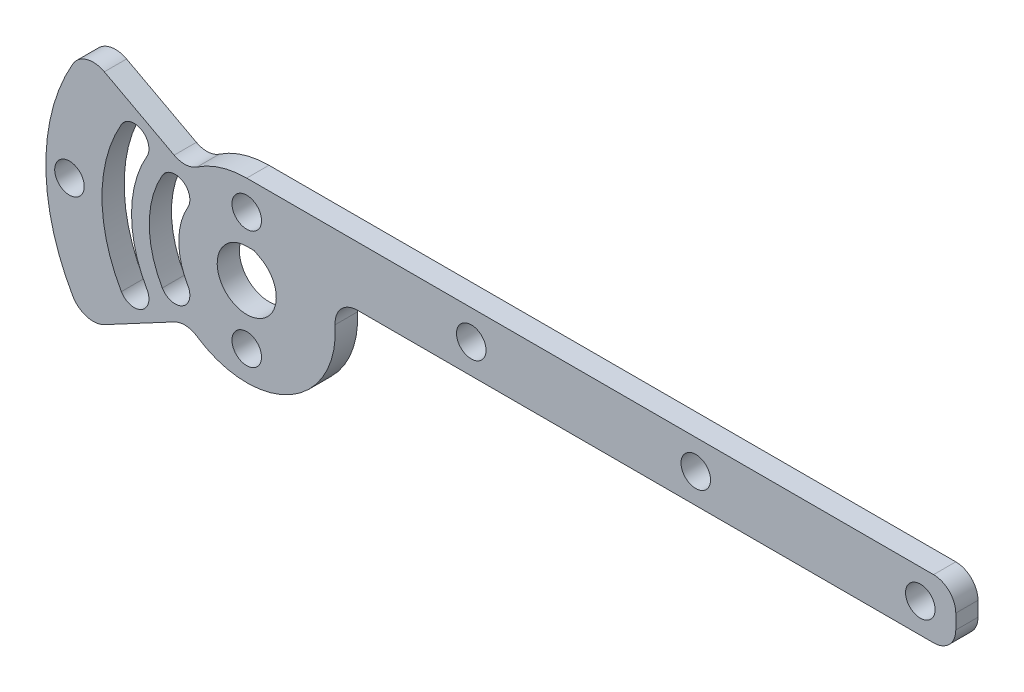
from build123d import *

# Parameters (mm, degrees)
SKETCH1_R           = 3.175
BOSS_EXTRUDE1_DEPTH = 4.7752
FILLET1_R           = 4.7752
SKETCH2_R           = 3.175
CUT_EXTRUDE2_DEPTH  = 12.6492


with BuildPart() as part:
    # Sketch1 → Boss-Extrude1 (new body)
    with BuildSketch(Plane.XY):
        with BuildLine():
            ThreePointArc((-37.394976935, 21.59), (-43.18, 0), (-37.394976935, -21.59))
            ThreePointArc((-37.394976935, -21.59), (-34.391979043, -23.934305056), (-30.603626356, -23.531630922))
            Line((-30.603626356, -23.531630922), (-12.85503117, -14.058829027))
            ThreePointArc((-12.85503117, -14.058829027), (10.51886685, -15.882567179), (17.960512242, 6.35))
            Line((17.960512242, 6.35), (152.4, 6.35))
            Line((152.4, 6.35), (152.4, 19.05))
            Line((152.4, 19.05), (0, 19.05))
            ThreePointArc((0, 19.05), (-6.89499119, 17.758423255), (-12.85503117, 14.058829027))
            Line((-12.85503117, 14.058829027), (-30.603626356, 23.531630922))
            ThreePointArc((-30.603626356, 23.531630922), (-34.391979043, 23.934305056), (-37.394976935, 21.59))
        make_face()
        with BuildLine():
            ThreePointArc((2.98992691, 5.602038653), (-1.541031238, -6.160172297), (0, 6.35))
            Line((0, 6.35), (1.588518614, 6.35))
            Line((1.588518614, 6.35), (2.98992691, 5.602038653))
        make_face(mode=Mode.SUBTRACT)
        with Locations((-38.1, 0)):
            Circle(SKETCH1_R, mode=Mode.SUBTRACT)
        with BuildLine():
            ThreePointArc((-26.946380439, -15.5575), (-31.115, 0), (-26.946380439, 15.5575))
            ThreePointArc((-26.946380439, 15.5575), (-22.609249782, 16.719630657), (-21.447119125, 12.3825))
            ThreePointArc((-21.447119125, 12.3825), (-24.765, 0), (-21.447119125, -12.3825))
            ThreePointArc((-21.447119125, -12.3825), (-22.609249782, -16.719630657), (-26.946380439, -15.5575))
        make_face(mode=Mode.SUBTRACT)
        with BuildLine():
            ThreePointArc((-18.147562336, -10.4775), (-20.955, 0), (-18.147562336, 10.4775))
            ThreePointArc((-18.147562336, 10.4775), (-13.810431679, 11.639630657), (-12.648301022, 7.3025))
            ThreePointArc((-12.648301022, 7.3025), (-14.605, 0), (-12.648301022, -7.3025))
            ThreePointArc((-12.648301022, -7.3025), (-13.810431679, -11.639630657), (-18.147562336, -10.4775))
        make_face(mode=Mode.SUBTRACT)
    extrude(amount=BOSS_EXTRUDE1_DEPTH)

    # Fillet1
    fillet1_edges = [part.edges().sort_by_distance(p)[0] for p in [
        (-12.85503117, 14.058829027, 2.3876),
        (152.4, 19.05, 2.3876),
        (152.4, 6.35, 2.3876),
        (17.960512242, 6.35, 2.3876),
        (-12.85503117, -14.058829027, 2.3876),
    ]]
    fillet(fillet1_edges, radius=FILLET1_R)

    # Sketch2 → Cut-Extrude2 (cut)
    with BuildSketch(Plane.XY.offset(4.7752)):
        with Locations((0, 12.7)):
            Circle(SKETCH2_R)
        with Locations((0, -12.7)):
            Circle(SKETCH2_R)
        with Locations((48.26, 12.7)):
            Circle(SKETCH2_R)
        with Locations((96.52, 12.7)):
            Circle(SKETCH2_R)
        with Locations((144.78, 12.7)):
            Circle(SKETCH2_R)
    extrude(amount=-CUT_EXTRUDE2_DEPTH, mode=Mode.SUBTRACT)


solid = part.part
